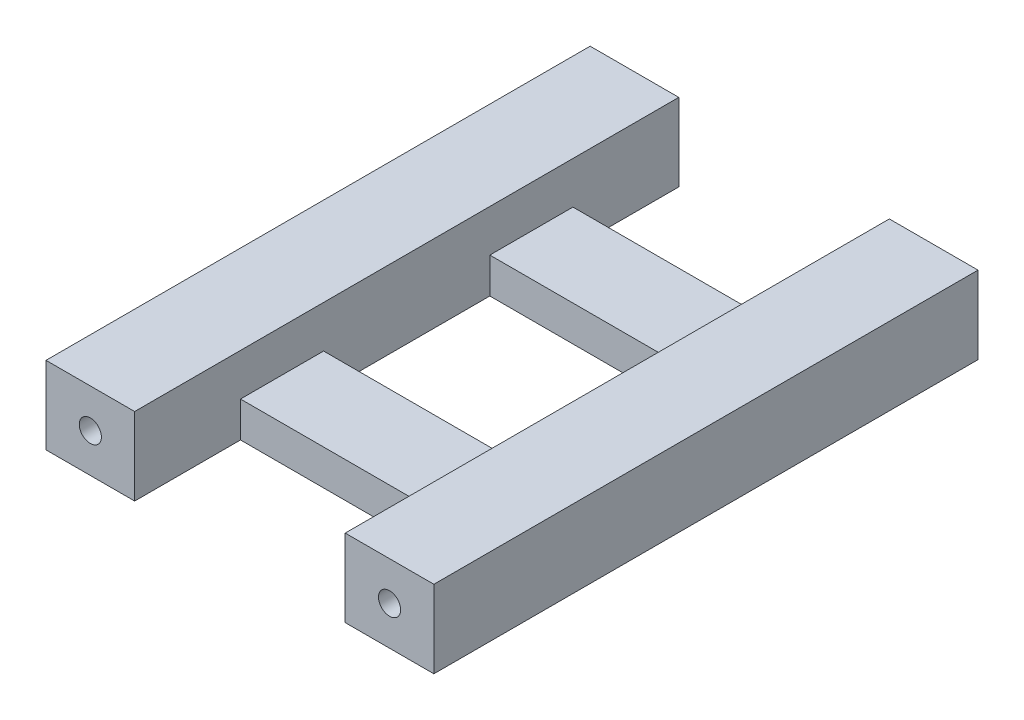
from build123d import *

# Parameters (mm, degrees)
CROQUIS1_W              = 19
CROQUIS1_H              = 15
SALIENTE_EXTRUIR1_DEPTH = 7
CROQUIS3_W              = 19
CROQUIS3_H              = 3.8
CORTAR_EXTRUIR1_DEPTH   = 37.9
CROQUIS4_R              = 1
CORTAR_EXTRUIR2_DEPTH   = 51.9


with BuildPart() as part:
    # Croquis1 → Saliente-Extruir1 (new body)
    with BuildSketch(Plane(origin=(0, 0, 0), x_dir=(1, 0, 0), z_dir=(0, 1, 0))):
        Polygon((16.592354246, -24.663454956), (16.592354246, 24.436543518), (8.592354246, 24.436543518), (8.592354246, 14.886544281), (-10.407645754, 14.886544281), (-10.407645754, 24.436543518), (-18.407645754, 24.436543518), (-18.407645754, -24.663454956), (-10.407645754, -24.663454956), (-10.407645754, -15.113455719), (8.592354246, -15.113455719), (8.592354246, -24.663454956), align=None)
        with Locations((-0.907645754, -0.113455719)):
            Rectangle(CROQUIS1_W, CROQUIS1_H, mode=Mode.SUBTRACT)
    extrude(amount=SALIENTE_EXTRUIR1_DEPTH)

    # Croquis3 → Cortar-Extruir1 (cut)
    with BuildSketch(Plane.XY.offset(15.113455719)):
        with Locations((-0.907645754, 5.1)):
            Rectangle(CROQUIS3_W, CROQUIS3_H)
    extrude(amount=-CORTAR_EXTRUIR1_DEPTH, mode=Mode.SUBTRACT)

    # Croquis4 → Cortar-Extruir2 (cut)
    with BuildSketch(Plane.XY.offset(24.663454956)):
        with Locations((12.592354246, 3.5)):
            Circle(CROQUIS4_R)
        with Locations((-14.407645754, 3.5)):
            Circle(CROQUIS4_R)
    extrude(amount=-CORTAR_EXTRUIR2_DEPTH, mode=Mode.SUBTRACT)


solid = part.part
